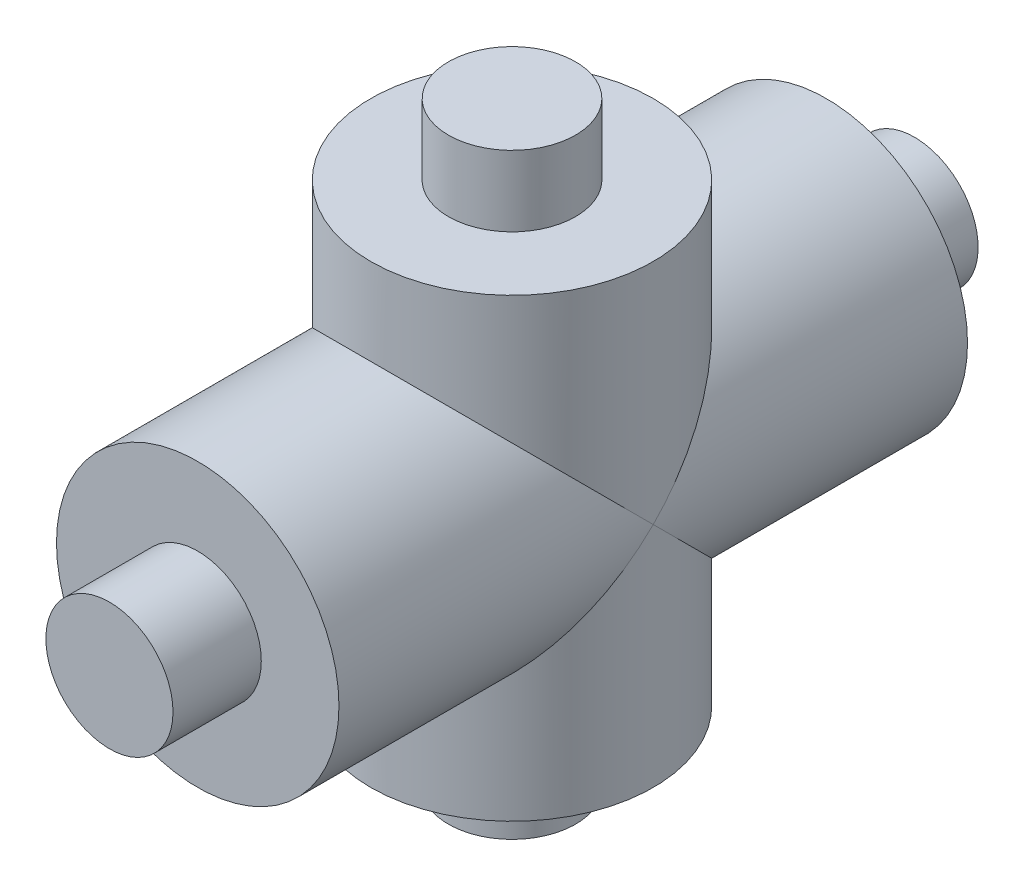
from build123d import *

# Parameters (mm, degrees)
SKETCH_1_R           = 4
EXTRUDE_1_DEPTH      = 17.8
SKETCH_2_R           = 1.8
EXTRUDE_2_DEPTH      = 2.5
EXTRUDE_START        = 2.5
SKETCH_3_R           = 1.8
EXTRUDE_3_DEPTH      = 2.5
EXTRUDE_4_DEPTH      = 6.45
EXTRUDE_4_DEPTH_BACK = 6.45
SKETCH_4_R           = 4
SKETCH_5_R           = 1.8
EXTRUDE_5_DEPTH      = 2
EXTRUDE_START_2      = 2
SKETCH_6_R           = 1.8
EXTRUDE_6_DEPTH      = 2


with BuildPart() as part:
    # 草图1 → 凸台-拉伸1 (new body)
    with BuildSketch(Plane.XY):
        Circle(SKETCH_1_R)
    extrude(amount=EXTRUDE_1_DEPTH)

    # 草图2 → 凸台-拉伸2 (add)
    with BuildSketch(Plane.XY.offset(17.8)):
        Circle(SKETCH_2_R)
    extrude(amount=EXTRUDE_2_DEPTH)

    # 草图3 → 凸台-拉伸3 (add)
    with BuildSketch(Plane(origin=(0, 0, 0), x_dir=(-1, 0, 0), z_dir=(0, 0, -1)).offset(EXTRUDE_START)):
        Circle(SKETCH_3_R)
    extrude(amount=-EXTRUDE_3_DEPTH)

    # 草图4 → 凸台-拉伸4 (add, two sides: drawn at the far end of the back side and taken through both)
    with BuildSketch(Plane(origin=(0, 0, 0), x_dir=(1, 0, 0), z_dir=(0, 1, 0)).offset(-EXTRUDE_4_DEPTH_BACK)):
        with Locations((0, -8.9)):
            Circle(SKETCH_4_R)
    extrude(amount=EXTRUDE_4_DEPTH + EXTRUDE_4_DEPTH_BACK)

    # 草图5 → 凸台-拉伸5 (add)
    with BuildSketch(Plane(origin=(0, -6.45, 0), x_dir=(-1, 0, 0), z_dir=(0, -1, 0))):
        with Locations((0, -8.9)):
            Circle(SKETCH_5_R)
    extrude(amount=EXTRUDE_5_DEPTH)

    # 草图6 → 凸台-拉伸6 (add)
    with BuildSketch(Plane(origin=(0, 6.45, 0), x_dir=(1, 0, 0), z_dir=(0, 1, 0)).offset(EXTRUDE_START_2)):
        with Locations((0, -8.9)):
            Circle(SKETCH_6_R)
    extrude(amount=-EXTRUDE_6_DEPTH)


solid = part.part
